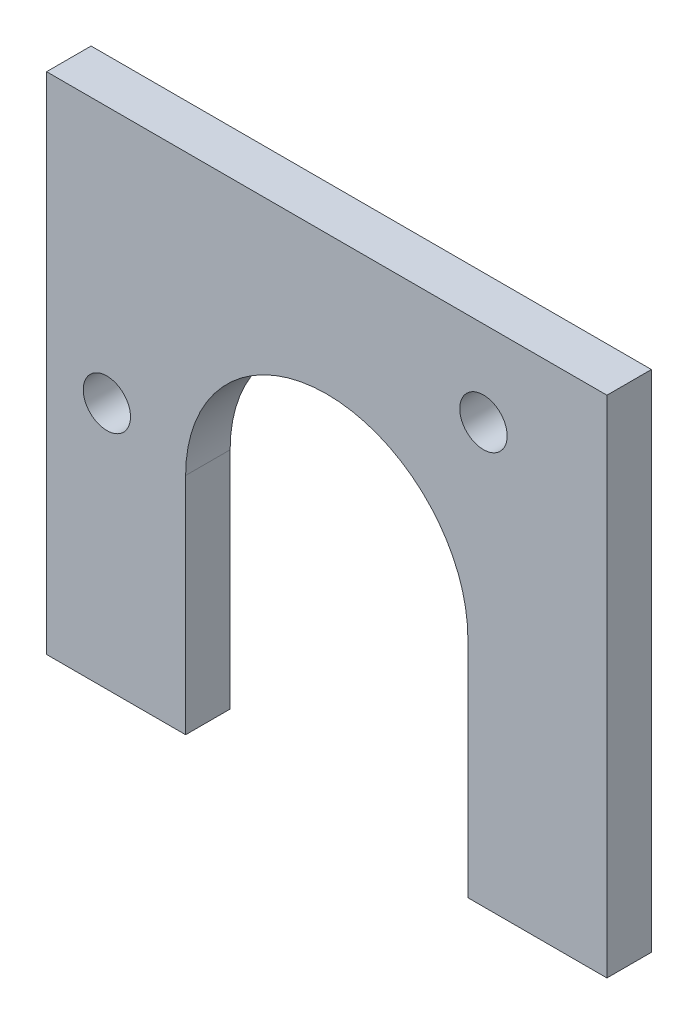
from build123d import *

# Parameters (mm, degrees)
BOSS_EXTRUDE1_DEPTH = 1.6
SKETCH2_R           = 0.852453889
SKETCH2_R_2         = 0.85
CUT_EXTRUDE1_DEPTH  = 3


with BuildPart() as part:
    # Sketch1 → Boss-Extrude1 (new body)
    with BuildSketch(Plane.XY):
        with BuildLine():
            Line((10.075, 5), (-10.075, 5))
            Line((-10.075, 5), (-10.075, -13.15))
            Line((-10.075, -13.15), (-5.075, -13.15))
            Line((-5.075, -13.15), (-5.075, -5.075))
            ThreePointArc((-5.075, -5.075), (0, 0), (5.075, -5.075))
            Line((5.075, -5.075), (5.075, -13.15))
            Line((5.075, -13.15), (10.075, -13.15))
            Line((10.075, -13.15), (10.075, 5))
        make_face()
    extrude(amount=BOSS_EXTRUDE1_DEPTH)

    # Sketch2 → Cut-Extrude1 (cut)
    with BuildSketch(Plane.XY.offset(1.6)):
        with Locations((5.634338394, 1.936419455)):
            Circle(SKETCH2_R)
        with Locations((-7.907828008, -4.242394056)):
            Circle(SKETCH2_R_2)
    extrude(amount=-CUT_EXTRUDE1_DEPTH, mode=Mode.SUBTRACT)


solid = part.part
